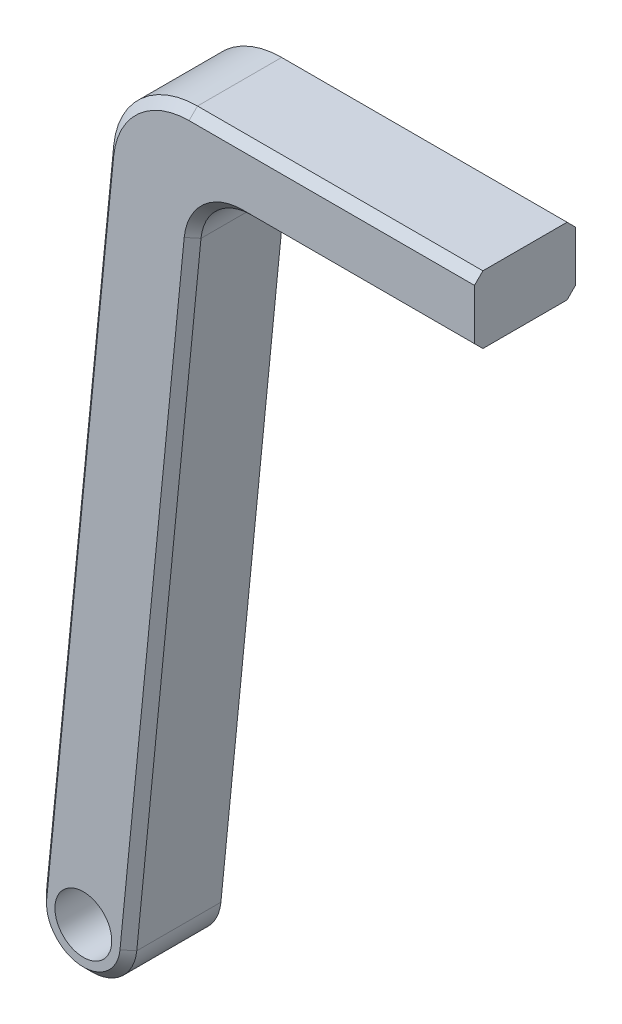
from build123d import *
from OCP.BRepFilletAPI import BRepFilletAPI_MakeFillet

# Parameters (mm, degrees)
SKETCH1_R           = 3.375
BOSS_EXTRUDE1_DEPTH = 12
FILLET1_R1          = 10
FILLET1_R2          = 6
CHAMFER1_SIZE       = 1


with BuildPart() as part:
    # Sketch1 → Boss-Extrude1 (new body)
    with BuildSketch(Plane.XY):
        with BuildLine():
            Line((3.505234224, 90), (-5.348872315, 0.529329726))
            ThreePointArc((-5.348872315, 0.529329726), (-0.529329726, -5.348872315), (5.348872315, -0.529329726))
            Line((5.348872315, -0.529329726), (13.516056888, 82))
            Line((13.516056888, 82), (46.473934517, 82))
            Line((46.473934517, 82), (46.473934517, 90))
            Line((46.473934517, 90), (3.505234224, 90))
        make_face()
        Circle(SKETCH1_R, mode=Mode.SUBTRACT)
    extrude(amount=BOSS_EXTRUDE1_DEPTH)

    # Fillet1: one fillet with a radius per group of edges: ONE call of the kernel's fillet builder (fillet() takes one radius for all edges)
    fillet1_edges_1 = [part.edges().sort_by_distance(p)[0] for p in [
        (3.505234224, 90, 6),
    ]]
    fillet1_edges_2 = [part.edges().sort_by_distance(p)[0] for p in [
        (13.516056888, 82, 6),
    ]]
    fillet1 = BRepFilletAPI_MakeFillet(part.part.solid().wrapped)
    for e in fillet1_edges_1:
        fillet1.Add(FILLET1_R1, e.wrapped)
    for e in fillet1_edges_2:
        fillet1.Add(FILLET1_R2, e.wrapped)
    add(Compound.cast(fillet1.Shape()), mode=Mode.REPLACE)

    # Chamfer1
    chamfer1_edges = [part.edges().sort_by_distance(p)[0] for p in [
        (32.712766845, 82, 0),
        (14.92327931, 80.446643575, 0),
        (9.164818638, 38.030774984, 0),
        (-0.529329726, -5.348872315, 0),
        (-1.367895651, 40.757064607, 0),
        (5.850604928, 87.411072625, 0),
        (29.519202941, 90, 0),
        (32.712766845, 82, 12),
        (14.92327931, 80.446643575, 12),
        (9.164818638, 38.030774984, 12),
        (-0.529329726, -5.348872315, 12),
        (-1.367895651, 40.757064607, 12),
        (5.850604928, 87.411072625, 12),
        (29.519202941, 90, 12),
    ]]
    chamfer(chamfer1_edges, length=CHAMFER1_SIZE)


solid = part.part
